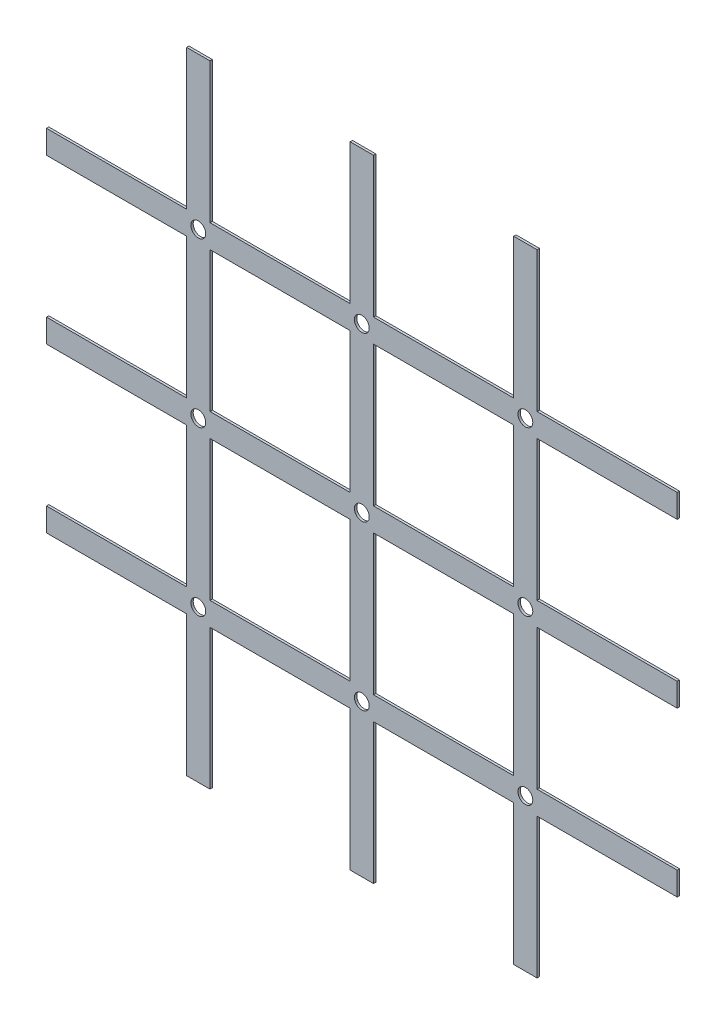
from build123d import *

# Parameters (mm, degrees)
ESQUISSE1_R        = 3.175
ESQUISSE1_W        = 60
ESQUISSE1_H        = 60
BOSS_EXTRU_1_DEPTH = 1


with BuildPart() as part:
    # Esquisse1 → Boss.-Extru.1 (new body)
    with BuildSketch(Plane.XY):
        Polygon((110, 310), (100, 310), (100, 250), (40, 250), (40, 240), (100, 240), (100, 180), (40, 180), (40, 170), (100, 170), (100, 110), (40, 110), (40, 100), (100, 100), (100, 40), (110, 40), (110, 100), (170, 100), (170, 40), (180, 40), (180, 100), (240, 100), (240, 40), (250, 40), (250, 100), (310, 100), (310, 110), (250, 110), (250, 170), (310, 170), (310, 180), (250, 180), (250, 240), (310, 240), (310, 250), (250, 250), (250, 310), (240, 310), (240, 250), (180, 250), (180, 310), (170, 310), (170, 250), (110, 250), align=None)
        with Locations((105, 105)):
            Circle(ESQUISSE1_R, mode=Mode.SUBTRACT)
        with Locations((140, 140)):
            Rectangle(ESQUISSE1_W, ESQUISSE1_H, mode=Mode.SUBTRACT)
        with Locations((105, 175)):
            Circle(ESQUISSE1_R, mode=Mode.SUBTRACT)
        with Locations((140, 210)):
            Rectangle(ESQUISSE1_W, ESQUISSE1_H, mode=Mode.SUBTRACT)
        with Locations((105, 245)):
            Circle(ESQUISSE1_R, mode=Mode.SUBTRACT)
        with Locations((175, 245)):
            Circle(ESQUISSE1_R, mode=Mode.SUBTRACT)
        with Locations((175, 105)):
            Circle(ESQUISSE1_R, mode=Mode.SUBTRACT)
        with Locations((210, 140)):
            Rectangle(ESQUISSE1_W, ESQUISSE1_H, mode=Mode.SUBTRACT)
        with Locations((245, 105)):
            Circle(ESQUISSE1_R, mode=Mode.SUBTRACT)
        with Locations((175, 175)):
            Circle(ESQUISSE1_R, mode=Mode.SUBTRACT)
        with Locations((210, 210)):
            Rectangle(ESQUISSE1_W, ESQUISSE1_H, mode=Mode.SUBTRACT)
        with Locations((245, 175)):
            Circle(ESQUISSE1_R, mode=Mode.SUBTRACT)
        with Locations((245, 245)):
            Circle(ESQUISSE1_R, mode=Mode.SUBTRACT)
    extrude(amount=BOSS_EXTRU_1_DEPTH)


solid = part.part
